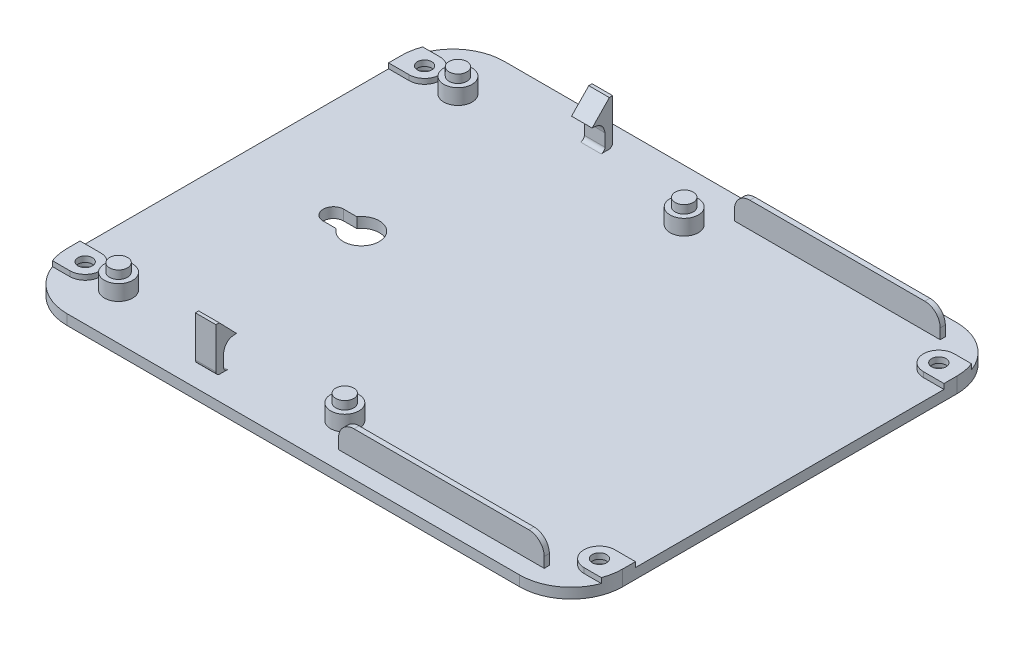
from build123d import *

# Parameters (mm, degrees)
BOSS_EXTRUDE2_DEPTH      = 2
CUT_EXTRUDE2_DEPTH       = 7
SKETCH10_W               = 40
SKETCH10_H               = 1
BOSS_EXTRUDE3_DEPTH      = 7
CUT_EXTRUDE4_DEPTH       = 1
CUT_EXTRUDE5_DEPTH       = 1
SKETCH14_R               = 1.75
BOSS_EXTRUDE4_DEPTH      = 6.600028
SKETCH15_R               = 2.75
BOSS_EXTRUDE5_DEPTH      = 5
BOSS_EXTRUDE7_DEPTH      = 2
BOSS_EXTRUDE7_DEPTH_BACK = 2
BOSS_EXTRUDE8_DEPTH      = 3
SKETCH21_R               = 3
CUT_EXTRUDE7_DEPTH       = 1.9
SKETCH22_R               = 1.4
CUT_EXTRUDE8_DEPTH       = 15


with BuildPart() as part:
    # Sketch3 → Boss-Extrude2 (new body)
    with BuildSketch(Plane(origin=(0, 0, 0), x_dir=(1, 0, 0), z_dir=(0, 1, 0))):
        with BuildLine():
            Line((-30.001043465, -34.015189653), (57.998956535, -34.015189653))
            ThreePointArc((57.998956535, -34.015189653), (65.070024347, -31.086257464), (67.998956535, -24.015189653))
            Line((67.998956535, -24.015189653), (67.998956535, 40.984810347))
            ThreePointArc((67.998956535, 40.984810347), (65.070024347, 48.055878159), (57.998956535, 50.984810347))
            Line((57.998956535, 50.984810347), (-30.001043465, 50.984810347))
            ThreePointArc((-30.001043465, 50.984810347), (-37.072111277, 48.055878159), (-40.001043465, 40.984810347))
            Line((-40.001043465, 40.984810347), (-40.001043465, -24.015189653))
            ThreePointArc((-40.001043465, -24.015189653), (-37.072111277, -31.086257464), (-30.001043465, -34.015189653))
        make_face()
    extrude(amount=BOSS_EXTRUDE2_DEPTH)

    # Sketch6 → Cut-Extrude2 (cut)
    with BuildSketch(Plane(origin=(0, 2, 0), x_dir=(1, 0, 0), z_dir=(0, 1, 0))):
        with BuildLine():
            Line((-18.182060551, 10.483778137), (-20.721753803, 10.483778137))
            ThreePointArc((-20.721753803, 10.483778137), (-22.720721593, 8.484810347), (-20.721753803, 6.485842558))
            Line((-20.721753803, 6.485842558), (-18.182060551, 6.485842558))
            ThreePointArc((-18.182060551, 6.485842558), (-11.809060764, 8.484810347), (-18.182060551, 10.483778137))
        make_face()
    extrude(amount=-CUT_EXTRUDE2_DEPTH, mode=Mode.SUBTRACT)

    # Sketch10 → Boss-Extrude3 (add)
    with BuildSketch(Plane(origin=(0, 0, 0), x_dir=(1, 0, 0), z_dir=(0, 1, 0))):
        with Locations((39.263184903, 46.984810347)):
            Rectangle(SKETCH10_W, SKETCH10_H)
        with Locations((39.263184903, -30.015189653)):
            Rectangle(SKETCH10_W, SKETCH10_H)
    extrude(amount=BOSS_EXTRUDE3_DEPTH)

    # Sketch12 → Cut-Extrude4 (cut)
    with BuildSketch(Plane.XY.offset(30.515189653)):
        with BuildLine():
            Line((56.263184903, 7), (59.263184903, 7))
            Line((59.263184903, 7), (59.263184903, 4))
            ThreePointArc((59.263184903, 4), (58.384505246, 6.121320344), (56.263184903, 7))
        make_face()
        with BuildLine():
            Line((19.263184903, 4), (19.263184903, 7))
            Line((19.263184903, 7), (22.263184903, 7))
            ThreePointArc((22.263184903, 7), (20.141864559, 6.121320344), (19.263184903, 4))
        make_face()
    extrude(amount=-CUT_EXTRUDE4_DEPTH, mode=Mode.SUBTRACT)

    # Sketch13 → Cut-Extrude5 (cut)
    with BuildSketch(Plane(origin=(0, 0, -47.484810347), x_dir=(-1, 0, 0), z_dir=(0, 0, -1))):
        with BuildLine():
            Line((-56.263184903, 7), (-59.263184903, 7))
            Line((-59.263184903, 7), (-59.263184903, 4))
            ThreePointArc((-59.263184903, 4), (-58.384505246, 6.121320344), (-56.263184903, 7))
        make_face()
        with BuildLine():
            Line((-19.263184903, 4), (-19.263184903, 7))
            Line((-19.263184903, 7), (-22.263184903, 7))
            ThreePointArc((-22.263184903, 7), (-20.141864559, 6.121320344), (-19.263184903, 4))
        make_face()
    extrude(amount=-CUT_EXTRUDE5_DEPTH, mode=Mode.SUBTRACT)

    # Sketch14 → Boss-Extrude4 (add)
    with BuildSketch(Plane.XZ):
        with Locations((-29.011006112, 25.011760646)):
            Circle(SKETCH14_R)
        with Locations((14.981881874, 25.011760646)):
            Circle(SKETCH14_R)
        with Locations((14.981881874, -40.988239354)):
            Circle(SKETCH14_R)
        with Locations((-29.011006112, -40.988239354)):
            Circle(SKETCH14_R)
    extrude(amount=-BOSS_EXTRUDE4_DEPTH)

    # Sketch15 → Boss-Extrude5 (add)
    with BuildSketch(Plane.XZ):
        with Locations((-29.011006112, 25.011760646)):
            Circle(SKETCH15_R)
        with Locations((14.981881874, 25.011760646)):
            Circle(SKETCH15_R)
        with Locations((14.981881874, -40.988239354)):
            Circle(SKETCH15_R)
        with Locations((-29.011006112, -40.988239354)):
            Circle(SKETCH15_R)
    extrude(amount=-BOSS_EXTRUDE5_DEPTH)

    # Sketch19 → Boss-Extrude7 (add, two sides)
    with BuildSketch(Plane(origin=(-7, 0, 0), x_dir=(0, 0, -1), z_dir=(1, 0, 0))) as boss_extrude7_sk:
        with BuildLine():
            add(Edge.make_bspline(
                [(45.56151484, 5.184913415), (45.252793653, 7.279810059), (43.062728824, 7.229305282)],
                knots=[0, 0, 0, 1, 1, 1], degree=2))
            Line((43.062728824, 7.229305282), (46.416379445, 10.690814493))
            Line((46.416379445, 10.690814493), (47.06151484, 10.690814493))
            Line((47.06151484, 10.690814493), (47.06151484, 2.75))
            ThreePointArc((47.06151484, 2.75), (46.841844926, 2.219669914), (46.31151484, 2))
            Line((46.31151484, 2), (46.31151484, 0))
            Line((46.31151484, 0), (44.81151484, 0))
            Line((44.81151484, 0), (44.81151484, 2))
            ThreePointArc((44.81151484, 2), (45.341844926, 2.219669914), (45.56151484, 2.75))
            Line((45.56151484, 2.75), (45.56151484, 5.184913415))
        make_face()
        with BuildLine():
            Line((-29.44675875, 10.690814493), (-30.091894145, 10.690814493))
            Line((-30.091894145, 10.690814493), (-30.091894145, 2.75))
            ThreePointArc((-30.091894145, 2.75), (-29.872224231, 2.219669914), (-29.341894145, 2))
            Line((-29.341894145, 2), (-29.341894145, 0))
            Line((-29.341894145, 0), (-28.591894145, 0))
            Line((-28.591894145, 0), (-27.841894145, 0))
            Line((-27.841894145, 0), (-27.841894145, 2))
            ThreePointArc((-27.841894145, 2), (-28.372224231, 2.219669914), (-28.591894145, 2.75))
            Line((-28.591894145, 2.75), (-28.591894145, 5.184913415))
            add(Edge.make_bspline(
                [(-28.591894145, 5.184913415), (-28.283172958, 7.279810059), (-26.09310813, 7.229305282)],
                knots=[0, 0, 0, 1, 1, 1], degree=2))
            Line((-26.09310813, 7.229305282), (-29.44675875, 10.690814493))
        make_face()
    extrude(amount=BOSS_EXTRUDE7_DEPTH)
    extrude(boss_extrude7_sk.sketch, amount=-BOSS_EXTRUDE7_DEPTH_BACK)

    # Sketch5 → Boss-Extrude8 (add)
    with BuildSketch(Plane(origin=(0, 0, 34.015189653), x_dir=(1, 0, 0), z_dir=(0, 1, 0))):
        with BuildLine():
            Line((-36.001043465, 78.5), (-39.368540462, 78.5))
            ThreePointArc((-39.368540462, 78.5), (-39.841647358, 76.778346145), (-40.001043465, 75))
            Line((-40.001043465, 75), (-40.001043465, 72.5))
            Line((-40.001043465, 72.5), (-36.001043465, 72.5))
            ThreePointArc((-36.001043465, 72.5), (-33.001043465, 75.5), (-36.001043465, 78.5))
        make_face()
        with BuildLine():
            Line((63.998956535, 78.5), (67.366453533, 78.5))
            ThreePointArc((67.366453533, 78.5), (67.839560429, 76.778346145), (67.998956535, 75))
            Line((67.998956535, 75), (67.998956535, 72.5))
            Line((67.998956535, 72.5), (63.998956535, 72.5))
            ThreePointArc((63.998956535, 72.5), (60.998956535, 75.5), (63.998956535, 78.5))
        make_face()
        with BuildLine():
            Line((63.998956535, 12.5), (67.998956535, 12.5))
            Line((67.998956535, 12.5), (67.998956535, 10))
            ThreePointArc((67.998956535, 10), (67.839560429, 8.221653855), (67.366453533, 6.5))
            Line((67.366453533, 6.5), (63.998956535, 6.5))
            ThreePointArc((63.998956535, 6.5), (60.998956535, 9.5), (63.998956535, 12.5))
        make_face()
        with BuildLine():
            Line((-36.001043465, 12.5), (-40.001043465, 12.5))
            Line((-40.001043465, 12.5), (-40.001043465, 10))
            ThreePointArc((-40.001043465, 10), (-39.841647358, 8.221653855), (-39.368540462, 6.5))
            Line((-39.368540462, 6.5), (-36.001043465, 6.5))
            ThreePointArc((-36.001043465, 6.5), (-33.001043465, 9.5), (-36.001043465, 12.5))
        make_face()
    extrude(amount=BOSS_EXTRUDE8_DEPTH)

    # Sketch21 → Cut-Extrude7 (cut)
    with BuildSketch(Plane.XZ):
        with Locations((-36.001043465, 24.515189653)):
            Circle(SKETCH21_R)
        with Locations((63.998956535, 24.515189653)):
            Circle(SKETCH21_R)
        with Locations((63.998956535, -41.484810347)):
            Circle(SKETCH21_R)
        with Locations((-36.001043465, -41.484810347)):
            Circle(SKETCH21_R)
    extrude(amount=-CUT_EXTRUDE7_DEPTH, mode=Mode.SUBTRACT)

    # Sketch22 → Cut-Extrude8 (cut)
    with BuildSketch(Plane.XZ.offset(-1.9)):
        with Locations((-36.001043465, 24.515189653)):
            Circle(SKETCH22_R)
        with Locations((63.998956535, 24.515189653)):
            Circle(SKETCH22_R)
        with Locations((63.998956535, -41.484810347)):
            Circle(SKETCH22_R)
        with Locations((-36.001043465, -41.484810347)):
            Circle(SKETCH22_R)
    extrude(amount=-CUT_EXTRUDE8_DEPTH, mode=Mode.SUBTRACT)


solid = part.part
